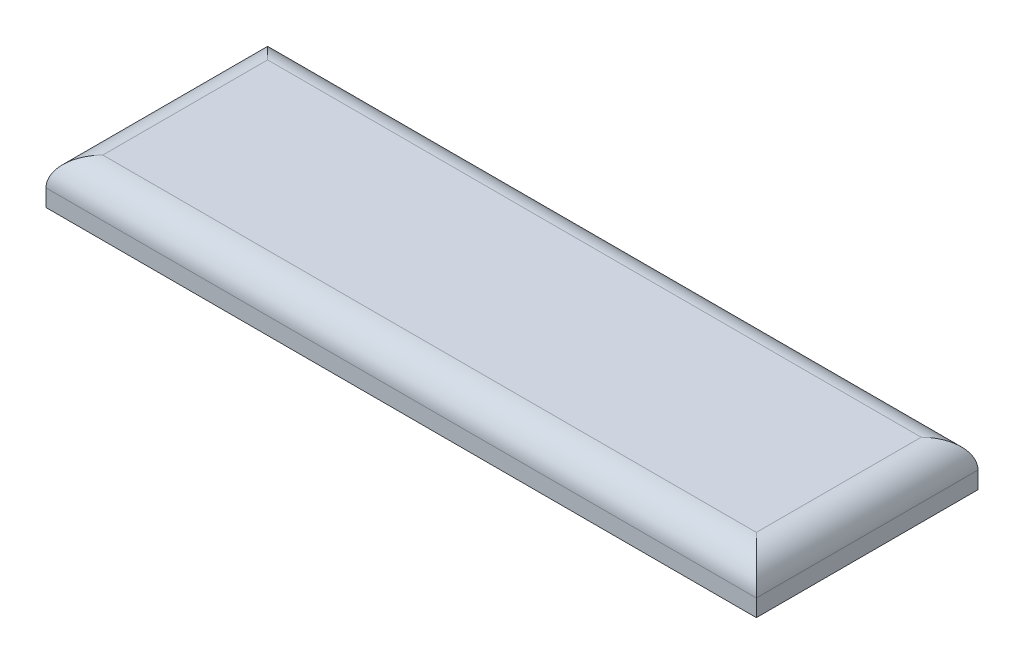
from build123d import *

# Parameters (mm, degrees)
SKETCH_1_W      = 25
SKETCH_1_H      = 7.8
EXTRUDE_1_DEPTH = 1.6
FILLET_1_R      = 1


with BuildPart() as part:
    # 草图1 → 凸台-拉伸1 (new body)
    with BuildSketch(Plane(origin=(0, 0, 0), x_dir=(1, 0, 0), z_dir=(0, 1, 0))):
        Rectangle(SKETCH_1_W, SKETCH_1_H)
    extrude(amount=EXTRUDE_1_DEPTH)

    # 圆角1
    fillet_1_edges = [part.edges().sort_by_distance(p)[0] for p in [
        (-12.5, 1.6, 0),
        (0, 1.6, 3.9),
        (12.5, 1.6, 0),
        (0, 1.6, -3.9),
    ]]
    fillet(fillet_1_edges, radius=FILLET_1_R)


solid = part.part
